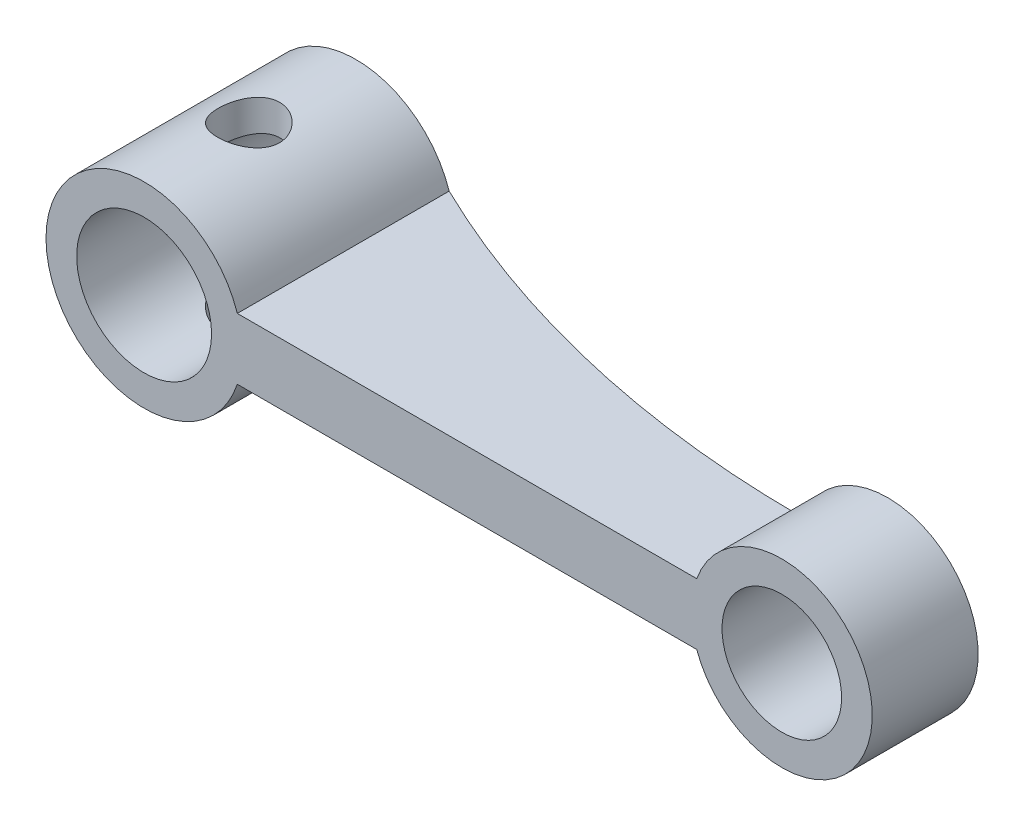
from build123d import *

# Parameters (mm, degrees)
SKETCH1_R              = 1.95
SKETCH1_R_2            = 2.2
MAIN_BODY_DEPTH        = 6.91
SKETCH2_R              = 1
TENDON_HOLE_DEPTH      = 10
MATERIAL_REMOVAL_DEPTH = 5


with BuildPart() as part:
    # Sketch1 → main body (new body)
    with BuildSketch(Plane.XY):
        with BuildLine():
            Line((-17.760263169, -1), (-2.775337817, -1))
            ThreePointArc((-2.775337817, -1), (2.95, 0), (-2.775337817, 1))
            Line((-2.775337817, 1), (-17.760263169, 1))
            ThreePointArc((-17.760263169, 1), (-24, 0), (-17.760263169, -1))
        make_face()
        Circle(SKETCH1_R, mode=Mode.SUBTRACT)
        with Locations((-20.8, 0)):
            Circle(SKETCH1_R_2, mode=Mode.SUBTRACT)
    extrude(amount=MAIN_BODY_DEPTH)

    # Sketch2 → tendon hole (cut, symmetric)
    with BuildSketch(Plane.XZ.offset(1)):
        with Locations((-20.840065792, 3.455)):
            Circle(SKETCH2_R)
    extrude(amount=TENDON_HOLE_DEPTH, both=True, mode=Mode.SUBTRACT)

    # Sketch3 → material removal (cut, symmetric)
    with BuildSketch(Plane.XZ.offset(1)):
        with BuildLine():
            Line((-2.775337817, 3.455), (2.95, 3.455))
            Line((2.95, 3.455), (2.95, 0))
            Line((2.95, 0), (-2.775337817, 0))
            Line((-2.775337817, 0), (-17.760263169, 0))
            ThreePointArc((-17.760263169, 0), (-10.464372425, 2.580066057), (-2.775337817, 3.455))
        make_face()
    extrude(amount=MATERIAL_REMOVAL_DEPTH, both=True, mode=Mode.SUBTRACT)


solid = part.part
